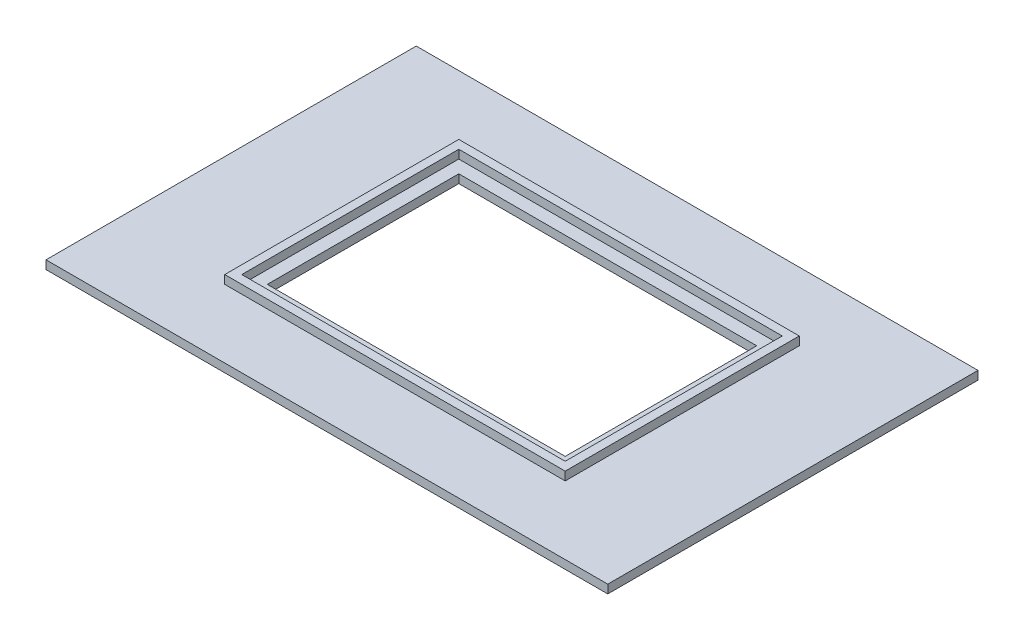
from build123d import *

# Parameters (mm, degrees)
SKETCH1_W           = 132
SKETCH1_H           = 87
BOSS_EXTRUDE1_DEPTH = 2
SKETCH2_W           = 80
SKETCH2_H           = 55
BOSS_EXTRUDE2_DEPTH = 2
SKETCH3_W           = 76
SKETCH3_H           = 51
CUT_EXTRUDE1_DEPTH  = 2
SKETCH4_W           = 70
SKETCH4_H           = 45
CUT_EXTRUDE2_DEPTH  = 2


with BuildPart() as part:
    # Sketch1 → Boss-Extrude1 (new body)
    with BuildSketch(Plane(origin=(0, 0, 0), x_dir=(1, 0, 0), z_dir=(0, 1, 0))):
        Rectangle(SKETCH1_W, SKETCH1_H)
    extrude(amount=BOSS_EXTRUDE1_DEPTH)

    # Sketch2 → Boss-Extrude2 (add)
    with BuildSketch(Plane(origin=(0, 2, 0), x_dir=(1, 0, 0), z_dir=(0, 1, 0))):
        Rectangle(SKETCH2_W, SKETCH2_H)
    extrude(amount=BOSS_EXTRUDE2_DEPTH)

    # Sketch3 → Cut-Extrude1 (cut)
    with BuildSketch(Plane(origin=(0, 4, 0), x_dir=(1, 0, 0), z_dir=(0, 1, 0))):
        Rectangle(SKETCH3_W, SKETCH3_H)
    extrude(amount=-CUT_EXTRUDE1_DEPTH, mode=Mode.SUBTRACT)

    # Sketch4 → Cut-Extrude2 (cut)
    with BuildSketch(Plane(origin=(0, 2, 0), x_dir=(1, 0, 0), z_dir=(0, 1, 0))):
        Rectangle(SKETCH4_W, SKETCH4_H)
    extrude(amount=-CUT_EXTRUDE2_DEPTH, mode=Mode.SUBTRACT)


solid = part.part
